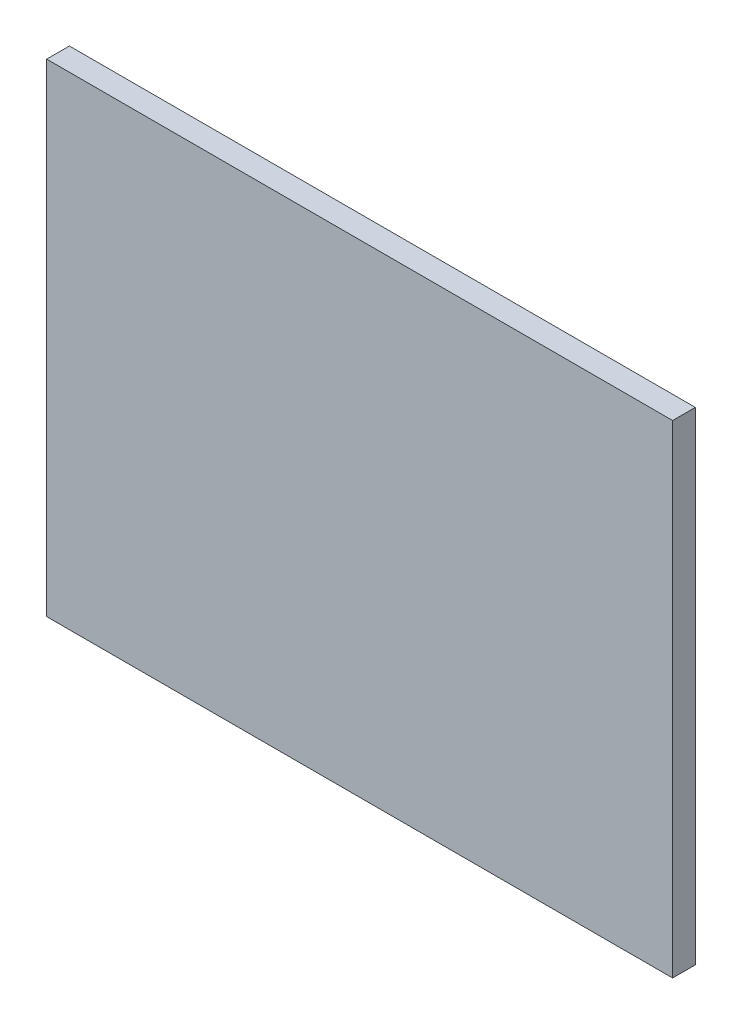
from build123d import *

# Parameters (mm, degrees)
SKETCH1_W           = 87.47
SKETCH1_H           = 67.47
BOSS_EXTRUDE1_DEPTH = 3.175


with BuildPart() as part:
    # Sketch1 → Boss-Extrude1 (new body)
    with BuildSketch(Plane.XY):
        Rectangle(SKETCH1_W, SKETCH1_H)
    extrude(amount=BOSS_EXTRUDE1_DEPTH)


solid = part.part
